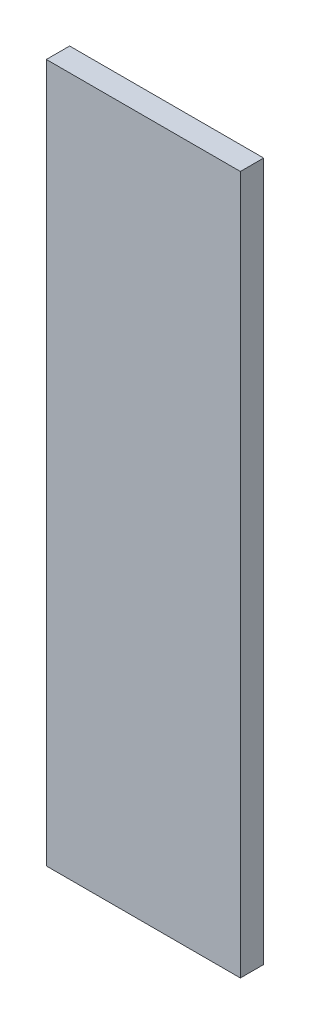
from build123d import *

# Parameters (mm, degrees)
CROQUIS1_W              = 50
CROQUIS1_H              = 180
SALIENTE_EXTRUIR1_DEPTH = 6


with BuildPart() as part:
    # Croquis1 → Saliente-Extruir1 (new body)
    with BuildSketch(Plane.XY):
        Rectangle(CROQUIS1_W, CROQUIS1_H)
    extrude(amount=SALIENTE_EXTRUIR1_DEPTH)


solid = part.part
